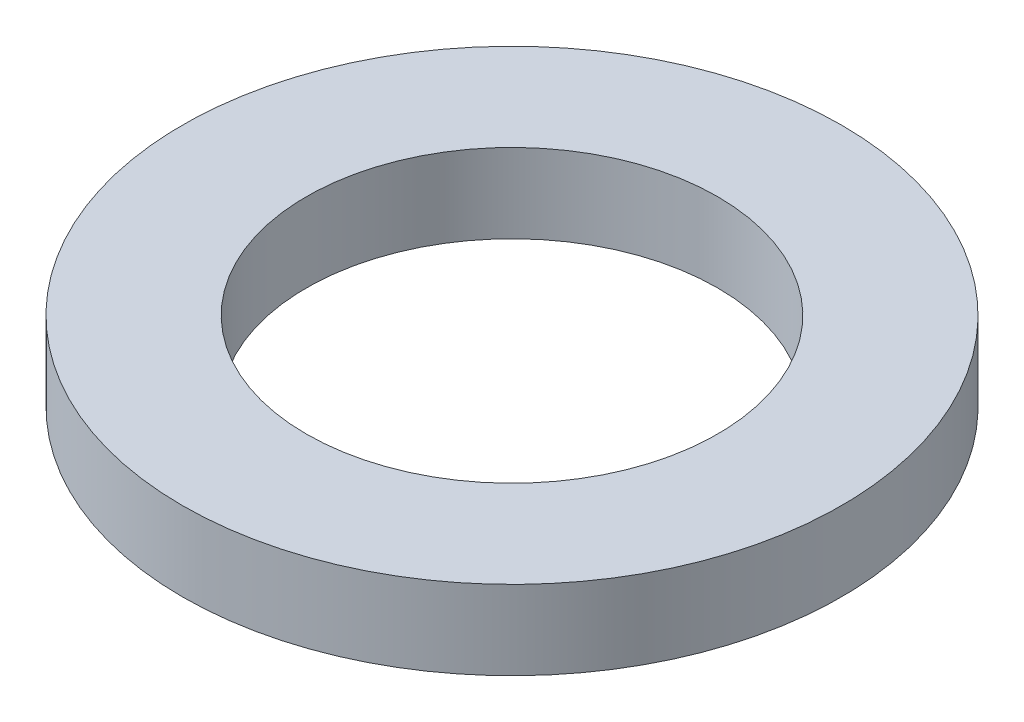
from build123d import *

# Parameters (mm, degrees)
SKETCH1_R           = 7.9375
BOSS_EXTRUDE1_DEPTH = 1.905
SKETCH5_R           = 4.953
CUT_EXTRUDE1_DEPTH  = 2.905


with BuildPart() as part:
    # Sketch1 → Boss-Extrude1 (new body)
    with BuildSketch(Plane(origin=(0, 0, 0), x_dir=(1, 0, 0), z_dir=(0, 1, 0))):
        Circle(SKETCH1_R)
    extrude(amount=BOSS_EXTRUDE1_DEPTH)

    # Sketch5 → Cut-Extrude1 (cut, through all)
    with BuildSketch(Plane(origin=(0, 1.905, 0), x_dir=(-1, 0, 0), z_dir=(0, 1, 0))):
        Circle(SKETCH5_R)
    extrude(amount=-CUT_EXTRUDE1_DEPTH, mode=Mode.SUBTRACT)


solid = part.part
